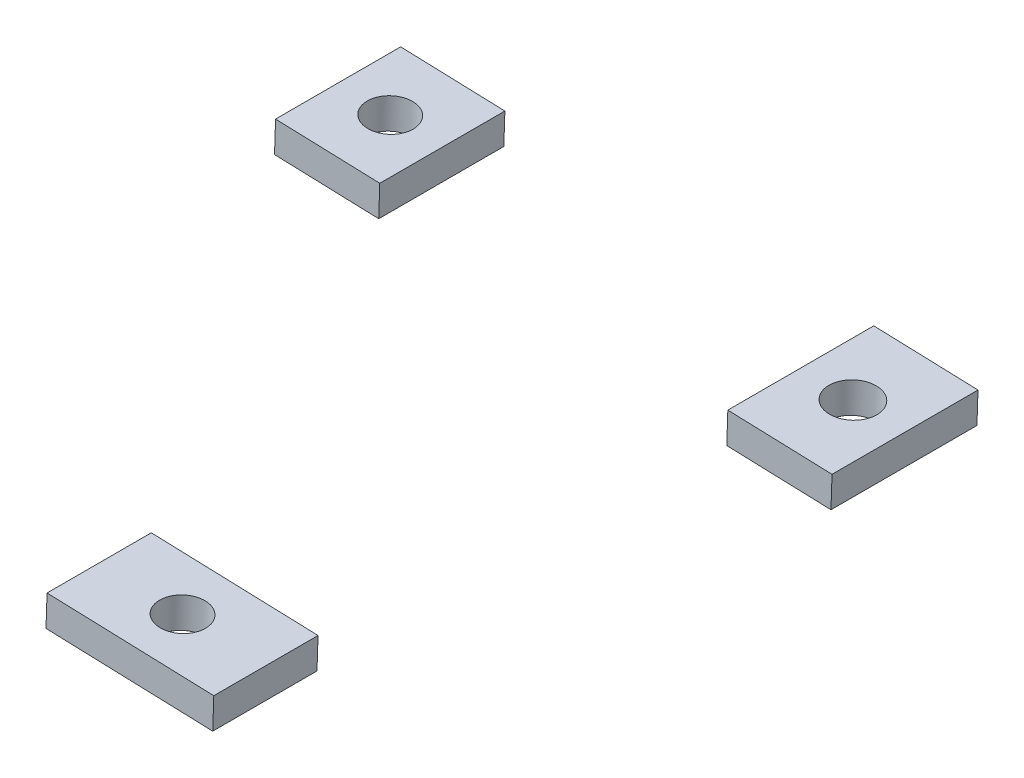
from build123d import *

# Parameters (mm, degrees)
SKETCH1_W             = 8
SKETCH1_H             = 5
SKETCH1_R             = 1.1
BOSS_EXTRUDE1_DEPTH   = 1.5
SKETCH1_W_2           = 5
SKETCH1_H_2           = 7
SKETCH1_R_2           = 1.15
BOSS_EXTRUDE1_2_DEPTH = 1.5
SKETCH1_H_3           = 6.00000012
BOSS_EXTRUDE1_3_DEPTH = 1.5


with BuildPart() as part:
    # Sketch1 → Boss-Extrude1 (new body)
    with BuildSketch(Plane(origin=(0.162307687, 4.851343176, 0), x_dir=(0.999440809, -0.033437529, 0), z_dir=(0.033437529, 0.999440809, 0))):
        with Locations((-112.136220146, -118.408907113)):
            Rectangle(SKETCH1_W, SKETCH1_H)
        with Locations((-112.136220146, -118.408907113)):
            Circle(SKETCH1_R, mode=Mode.SUBTRACT)
    extrude(amount=BOSS_EXTRUDE1_DEPTH)


with BuildPart() as body_2:
    # Sketch1 → Boss-Extrude1 2 (new body)
    with BuildSketch(Plane(origin=(0.162307687, 4.851343176, 0), x_dir=(0.999440809, -0.033437529, 0), z_dir=(0.033437529, 0.999440809, 0))):
        with Locations((-105.186219044, -93.208907417)):
            Rectangle(SKETCH1_W_2, SKETCH1_H_2)
        with Locations((-105.186219044, -93.208907417)):
            Circle(SKETCH1_R_2, mode=Mode.SUBTRACT)
    extrude(amount=BOSS_EXTRUDE1_2_DEPTH)


with BuildPart() as body_3:
    # Sketch1 → Boss-Extrude1 3 (new body)
    with BuildSketch(Plane(origin=(0.162307687, 4.851343176, 0), x_dir=(0.999440809, -0.033437529, 0), z_dir=(0.033437529, 0.999440809, 0))):
        with Locations((-127.386219044, -93.208906265)):
            Rectangle(SKETCH1_W_2, SKETCH1_H_3)
        with Locations((-127.386219044, -93.208906447)):
            Circle(SKETCH1_R, mode=Mode.SUBTRACT)
    extrude(amount=BOSS_EXTRUDE1_3_DEPTH)


solid = Compound([part.part, body_2.part, body_3.part])
